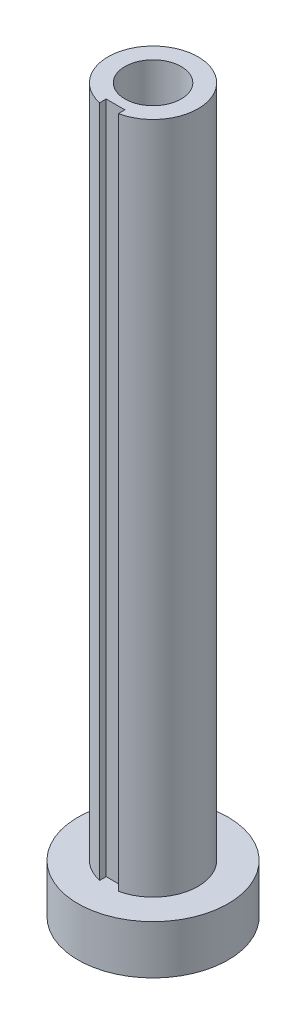
from build123d import *

# Parameters (mm, degrees)
SKETCH1_R               = 6.096
SKETCH1_R_2             = 3.81
BOSS_EXTRUDE1_DEPTH     = 97.79
SKETCH2_W               = 2.54
SKETCH2_H               = 1.627681679
CUT_EXTRUDE1_DEPTH      = 1
CUT_EXTRUDE1_DEPTH_BACK = 98.79
SKETCH3_R               = 10.16
SKETCH3_R_2             = 3.81
BOSS_EXTRUDE2_DEPTH     = 6.604


with BuildPart() as part:
    # Sketch1 → Boss-Extrude1 (new body)
    with BuildSketch(Plane(origin=(0, 0, 0), x_dir=(1, 0, 0), z_dir=(0, 1, 0))):
        Circle(SKETCH1_R)
        Circle(SKETCH1_R_2, mode=Mode.SUBTRACT)
    extrude(amount=BOSS_EXTRUDE1_DEPTH)

    # Sketch2 → Cut-Extrude1 (cut, two sides)
    with BuildSketch(Plane.XZ) as cut_extrude1_sk:
        with Locations((0, 5.89384084)):
            Rectangle(SKETCH2_W, SKETCH2_H)
    extrude(amount=CUT_EXTRUDE1_DEPTH, mode=Mode.SUBTRACT)
    extrude(cut_extrude1_sk.sketch, amount=-CUT_EXTRUDE1_DEPTH_BACK, mode=Mode.SUBTRACT)

    # Sketch3 → Boss-Extrude2 (add)
    with BuildSketch(Plane.XZ):
        Circle(SKETCH3_R)
        Circle(SKETCH3_R_2, mode=Mode.SUBTRACT)
    extrude(amount=-BOSS_EXTRUDE2_DEPTH)


solid = part.part
